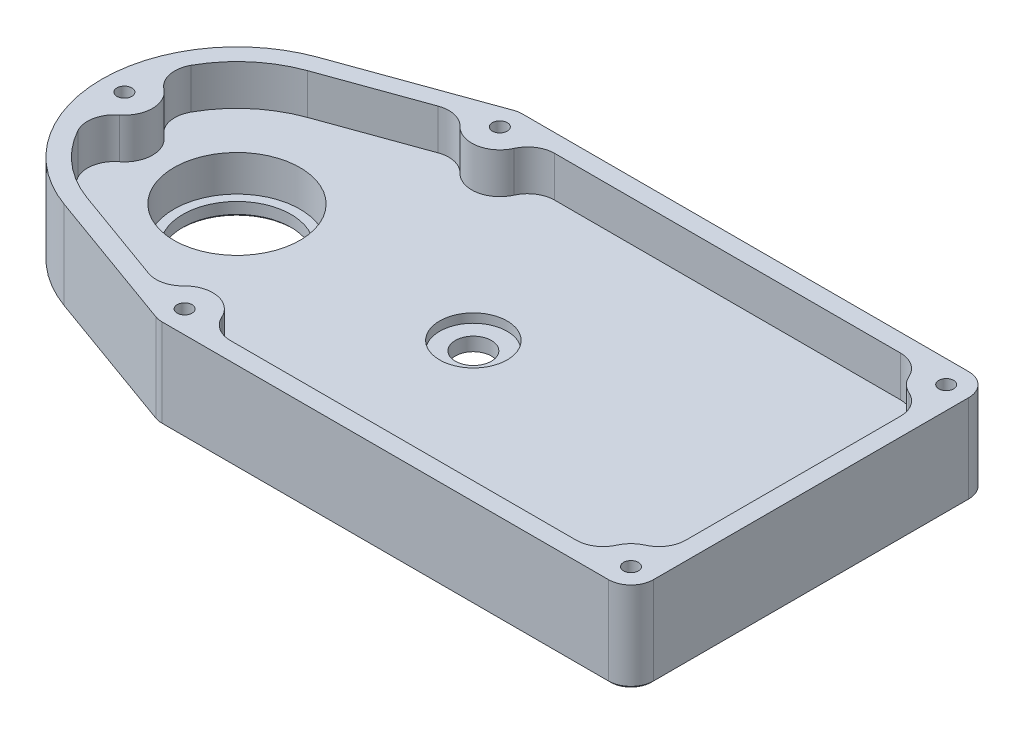
from build123d import *

# Parameters (mm, degrees)
SKETCH2_R                   = 4
SKETCH2_R_2                 = 12
BOSS_EXTRUDE1_DEPTH         = 20
FILLET1_R                   = 5
SKETCH2_3_R                 = 4
CUT_EXTRUDE1_DEPTH          = 6
SKETCH3_R                   = 14
CUT_EXTRUDE2_DEPTH          = 17
SKETCH4_R                   = 7.5
CUT_EXTRUDE3_DEPTH          = 11
TAP_DRILL_FOR_M4_TAP1_D     = 3.3
TAP_DRILL_FOR_M4_TAP1_DEPTH = 13
TAP_DRILL_FOR_M4_TAP1_TIP   = 0.991420021
CUT_EXTRUDE4_DEPTH          = 9
FILLET2_R                   = 6
CHAMFER1_SIZE               = 0.5


with BuildPart() as part:
    # Sketch2 → Boss-Extrude1 (new body)
    with BuildSketch(Plane(origin=(0, 0, 0), x_dir=(1, 0, 0), z_dir=(0, 1, 0))):
        with BuildLine():
            Line((-30, 40), (75, 40))
            Line((75, 40), (75, -40))
            Line((75, -40), (-30, -40))
            Line((-30, -40), (-62.673213991, -28.22243287))
            ThreePointArc((-62.673213991, -28.22243287), (-82.5, 0), (-62.673213991, 28.22243287))
            Line((-62.673213991, 28.22243287), (-30, 40))
        make_face()
        Circle(SKETCH2_R, mode=Mode.SUBTRACT)
        with Locations((-52.5, 0)):
            Circle(SKETCH2_R_2, mode=Mode.SUBTRACT)
    extrude(amount=BOSS_EXTRUDE1_DEPTH)

    # Fillet1
    fillet1_edges = [part.edges().sort_by_distance(p)[0] for p in [
        (-30, 10, -40),
        (75, 10, -40),
        (75, 10, 40),
        (-30, 10, 40),
    ]]
    fillet(fillet1_edges, radius=FILLET1_R)

    # Sketch2_3 → Cut-Extrude1 (cut)
    with BuildSketch(Plane(origin=(0, 0, 0), x_dir=(1, 0, 0), z_dir=(0, 1, 0))):
        with BuildLine():
            Line((22.6, -19.6), (22.6, 19.6))
            ThreePointArc((22.6, 19.6), (21.721320344, 21.721320344), (19.6, 22.6))
            Line((19.6, 22.6), (-19.6, 22.6))
            ThreePointArc((-19.6, 22.6), (-21.721320344, 21.721320344), (-22.6, 19.6))
            Line((-22.6, 19.6), (-22.6, -19.6))
            ThreePointArc((-22.6, -19.6), (-21.721320344, -21.721320344), (-19.6, -22.6))
            Line((-19.6, -22.6), (19.6, -22.6))
            ThreePointArc((19.6, -22.6), (21.721320344, -21.721320344), (22.6, -19.6))
        make_face()
        Circle(SKETCH2_3_R, mode=Mode.SUBTRACT)
    extrude(amount=CUT_EXTRUDE1_DEPTH, mode=Mode.SUBTRACT)

    # Sketch3 → Cut-Extrude2 (cut)
    with BuildSketch(Plane(origin=(0, 20, 0), x_dir=(1, 0, 0), z_dir=(0, 1, 0))):
        with Locations((-52.5, 0)):
            Circle(SKETCH3_R)
    extrude(amount=-CUT_EXTRUDE2_DEPTH, mode=Mode.SUBTRACT)

    # Sketch4 → Cut-Extrude3 (cut)
    with BuildSketch(Plane(origin=(0, 20, 0), x_dir=(1, 0, 0), z_dir=(0, 1, 0))):
        Circle(SKETCH4_R)
    extrude(amount=-CUT_EXTRUDE3_DEPTH, mode=Mode.SUBTRACT)

    # Tap Drill for M4 Tap1
    with Locations(Plane(origin=(0, 20, 0), x_dir=(1, 0, 0), z_dir=(0, 1, 0))):
        with Locations((70, 35), (-77.5, 0), (-29.126349288, 35), (-29.126349288, -35), (70, -35)):
            Hole(TAP_DRILL_FOR_M4_TAP1_D / 2, depth=TAP_DRILL_FOR_M4_TAP1_DEPTH)
            with Locations((0, 0, -(TAP_DRILL_FOR_M4_TAP1_DEPTH + TAP_DRILL_FOR_M4_TAP1_TIP / 2))):  # 118° drill point
                Cone(0, TAP_DRILL_FOR_M4_TAP1_D / 2, TAP_DRILL_FOR_M4_TAP1_TIP, mode=Mode.SUBTRACT)

    # Sketch7 → Cut-Extrude4 (cut)
    with BuildSketch(Plane(origin=(0, 20, 0), x_dir=(1, 0, 0), z_dir=(0, 1, 0))):
        with BuildLine():
            Line((-61.316785459, -24.459441821), (-35.269382186, -33.848632633))
            ThreePointArc((-35.269382186, -33.848632633), (-28.050584319, -28.843277679), (-22.956867948, -36))
            Line((-22.956867948, -36), (63.83051866, -36))
            ThreePointArc((63.83051866, -36), (65.580582618, -30.580582618), (71, -28.83051866))
            Line((71, -28.83051866), (71, 28.83051866))
            ThreePointArc((71, 28.83051866), (65.580582618, 30.580582618), (63.83051866, 36))
            Line((63.83051866, 36), (-22.956867948, 36))
            ThreePointArc((-22.956867948, 36), (-28.050584319, 28.843277679), (-35.269382186, 33.848632633))
            Line((-35.269382186, 33.848632633), (-61.316785459, 24.459441821))
            ThreePointArc((-61.316785459, 24.459441821), (-71.810161981, 17.410274101), (-77.73875, 6.24543821))
            ThreePointArc((-77.73875, 6.24543821), (-71.25, 0), (-77.73875, -6.24543821))
            ThreePointArc((-77.73875, -6.24543821), (-71.810161981, -17.410274101), (-61.316785459, -24.459441821))
        make_face()
    extrude(amount=-CUT_EXTRUDE4_DEPTH, mode=Mode.SUBTRACT)

    # Fillet2
    fillet2_edges = [part.edges().sort_by_distance(p)[0] for p in [
        (71, 15.5, 28.83051866),
        (63.83051866, 15.5, 36),
        (-22.956867948, 15.5, 36),
        (-35.269382186, 15.5, 33.848632633),
        (-77.73875, 15.5, 6.24543821),
        (-77.73875, 15.5, -6.24543821),
        (-35.269382186, 15.5, -33.848632633),
        (-22.956867948, 15.5, -36),
        (63.83051866, 15.5, -36),
        (71, 15.5, -28.83051866),
    ]]
    fillet(fillet2_edges, radius=FILLET2_R)

    # Chamfer1
    chamfer1_edges = [part.edges().sort_by_distance(p)[0] for p in [
        (-46.747549472, 0, 33.963085841),
        (-82.5, 0, 0),
        (-64.5, 0, 0),
        (20.436825356, 0, 40),
        (-46.747549472, 0, -33.963085841),
        (20.436825356, 0, -40),
        (75, 0, 0),
        (-29.986961262, 0, -39.925377856),
        (73.535533906, 0, -38.535533906),
        (73.535533906, 0, 38.535533906),
        (-29.986961262, 0, 39.925377856),
        (22.6, 0, 0),
        (21.721320344, 0, -21.721320344),
        (0, 0, -22.6),
        (-21.721320344, 0, -21.721320344),
        (21.721320344, 0, 21.721320344),
        (0, 0, 22.6),
        (-21.721320344, 0, 21.721320344),
        (-22.6, 0, 0),
    ]]
    chamfer(chamfer1_edges, length=CHAMFER1_SIZE)


solid = part.part
